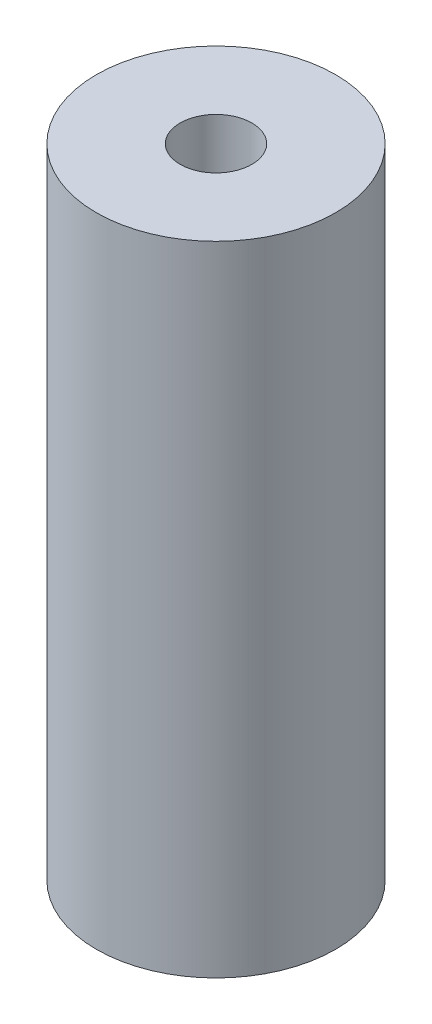
from build123d import *

# Parameters (mm, degrees)
SKETCH1_R           = 7.5
SKETCH1_R_2         = 2.25
BOSS_EXTRUDE1_DEPTH = 40


with BuildPart() as part:
    # Sketch1 → Boss-Extrude1 (new body)
    with BuildSketch(Plane(origin=(0, 0, 0), x_dir=(1, 0, 0), z_dir=(0, 1, 0))):
        Circle(SKETCH1_R)
        Circle(SKETCH1_R_2, mode=Mode.SUBTRACT)
    extrude(amount=BOSS_EXTRUDE1_DEPTH)


solid = part.part
